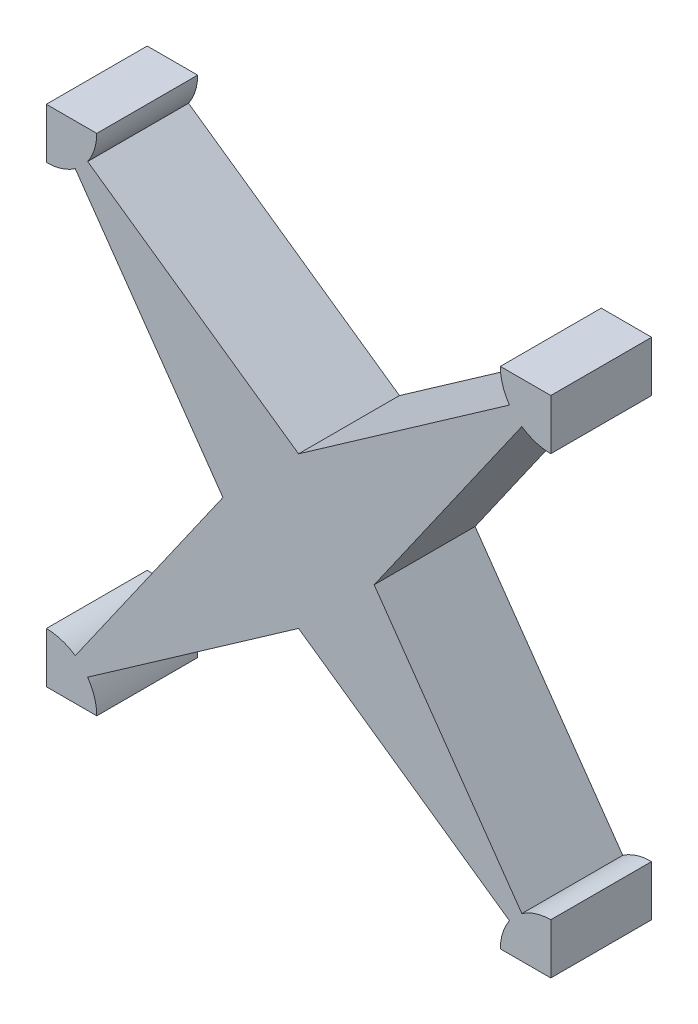
from build123d import *

# Parameters (mm, degrees)
BOSS_EXTRUDE1_DEPTH = 5
BOSS_EXTRUDE2_DEPTH = 5


with BuildPart() as part:
    # Sketch1 → Boss-Extrude1 (new body)
    with BuildSketch(Plane.XY):
        Polygon((0, 0), (8.752594228, 12.5), (0, 25), (12.5, 16.247405772), (25, 25), (16.247405772, 12.5), (25, 0), (12.5, 8.752594228), align=None)
    extrude(amount=BOSS_EXTRUDE1_DEPTH)

    # Sketch2 → Boss-Extrude2 (add)
    with BuildSketch(Plane.XY.offset(5)):
        with BuildLine():
            Line((0, 22.5), (0, 25))
            Line((0, 25), (2.5, 25))
            ThreePointArc((2.5, 25), (1.767766953, 23.232233047), (0, 22.5))
        make_face()
        with BuildLine():
            Line((25, 22.5), (25, 25))
            Line((25, 25), (22.5, 25))
            ThreePointArc((22.5, 25), (23.232233047, 23.232233047), (25, 22.5))
        make_face()
        with BuildLine():
            Line((25, 0), (22.5, 0))
            ThreePointArc((22.5, 0), (23.232233047, 1.767766953), (25, 2.5))
            Line((25, 2.5), (25, 0))
        make_face()
        with BuildLine():
            Line((0, 2.5), (0, 0))
            Line((0, 0), (2.5, 0))
            ThreePointArc((2.5, 0), (1.767766953, 1.767766953), (0, 2.5))
        make_face()
    extrude(amount=-BOSS_EXTRUDE2_DEPTH)


solid = part.part
